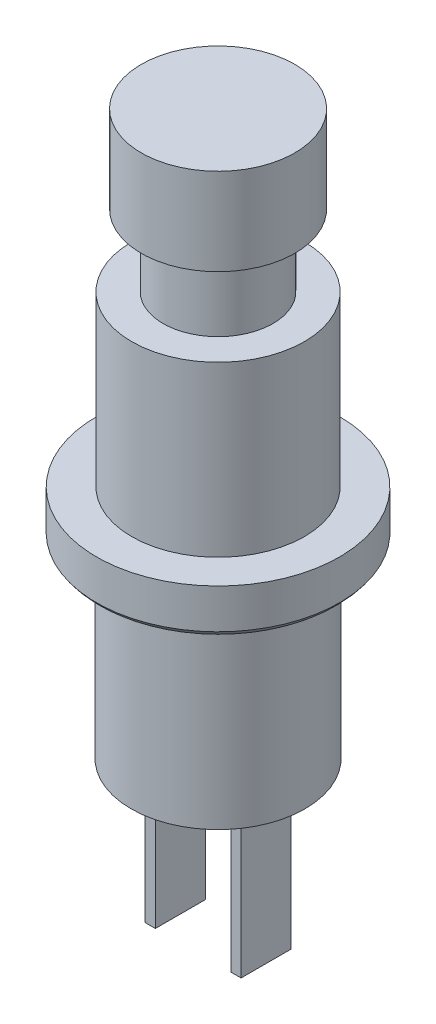
from build123d import *

# Parameters (mm, degrees)
SKETCH2_W           = 0.4
SKETCH2_H           = 1.95
BOSS_EXTRUDE1_DEPTH = 6


with BuildPart() as part:
    # Sketch1 → Revolve1 (revolve)
    with BuildSketch(Plane.XY):
        with BuildLine():
            Line((0, 0), (3, 0))
            Line((3, 0), (3, -3.4))
            Line((3, -3.4), (2.15, -3.4))
            Line((2.15, -3.4), (2.15, -6.2))
            Line((2.15, -6.2), (3.375, -6.2))
            Line((3.375, -6.2), (3.375, -12.8))
            Line((3.375, -12.8), (4.75, -12.8))
            Line((4.75, -12.8), (4.75, -14.35))
            ThreePointArc((4.75, -14.35), (4.389176995, -14.680340843), (3.914835346, -14.8))
            Line((3.914835346, -14.8), (3.4, -14.8))
            Line((3.4, -14.8), (3.4, -22))
            Line((3.4, -22), (0, -22))
            Line((0, -22), (0, 0))
        make_face()
    revolve(axis=Axis((0, -223.623157896, 0), (0, 1, 0)))

    # Sketch2 → Boss-Extrude1 (add)
    with BuildSketch(Plane.XZ.offset(22)):
        with Locations((-1.675, 0)):
            Rectangle(SKETCH2_W, SKETCH2_H)
        with Locations((1.675, 0)):
            Rectangle(SKETCH2_W, SKETCH2_H)
    extrude(amount=BOSS_EXTRUDE1_DEPTH)


solid = part.part
